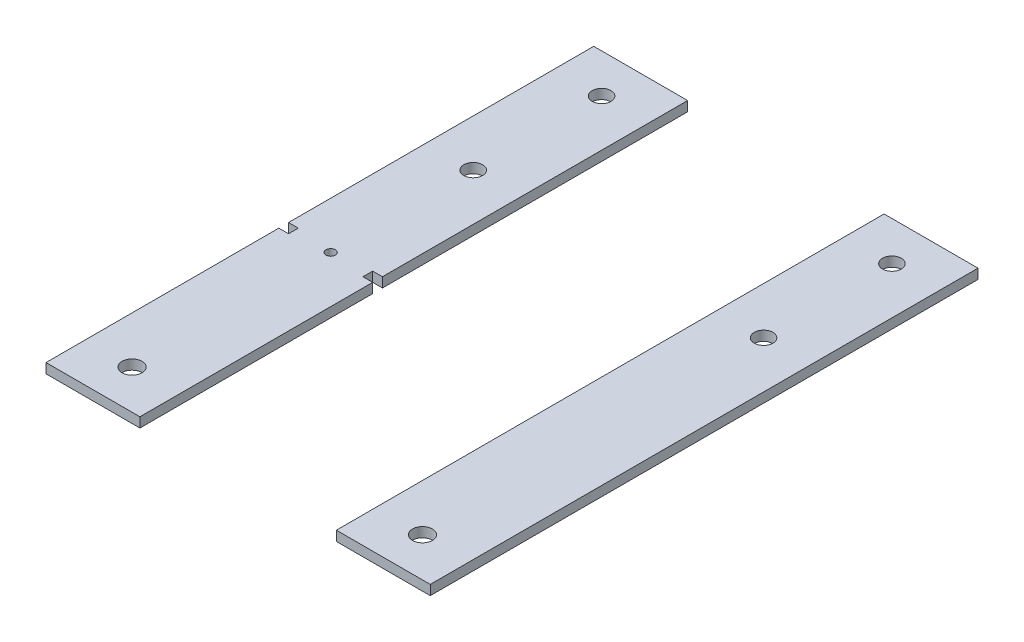
from build123d import *

# Parameters (mm, degrees)
SKETCH1_R             = 1.524
SKETCH1_R_2           = 3.048
SKETCH1_R_3           = 3.2385
BOSS_EXTRUDE1_DEPTH   = 3.175
SKETCH1_W             = 30.48
SKETCH1_H             = 177.8
BOSS_EXTRUDE1_2_DEPTH = 3.175


with BuildPart() as part:
    # Sketch1 → Boss-Extrude1 (new body)
    with BuildSketch(Plane(origin=(0, 0, 0), x_dir=(1, 0, 0), z_dir=(0, 1, 0))):
        Polygon((-31.884999984, 88.9), (-31.884999984, -10.16), (-35.059999984, -10.16), (-35.059999984, -13.335), (-31.884999984, -13.335), (-31.884999984, -88.9), (-62.364999984, -88.9), (-62.364999984, -13.335), (-59.189999984, -13.335), (-59.189999984, -10.16), (-62.364999984, -10.16), (-62.364999984, 88.9), align=None)
        with Locations((-47.124999984, -11.7475)):
            Circle(SKETCH1_R, mode=Mode.SUBTRACT)
        with Locations((-47.124999984, 34.529268)):
            Circle(SKETCH1_R_2, mode=Mode.SUBTRACT)
        with Locations((-47.124999984, 76.2)):
            Circle(SKETCH1_R_2, mode=Mode.SUBTRACT)
        with Locations((-47.124999984, -76.2)):
            Circle(SKETCH1_R_3, mode=Mode.SUBTRACT)
    extrude(amount=BOSS_EXTRUDE1_DEPTH)


with BuildPart() as body_2:
    # Sketch1 → Boss-Extrude1 2 (new body)
    with BuildSketch(Plane(origin=(0, 0, 0), x_dir=(1, 0, 0), z_dir=(0, 1, 0))):
        with Locations((47.124999984, 0)):
            Rectangle(SKETCH1_W, SKETCH1_H)
        with Locations((47.124999984, 76.2)):
            Circle(SKETCH1_R_2, mode=Mode.SUBTRACT)
        with Locations((47.124999984, 34.529268)):
            Circle(SKETCH1_R_2, mode=Mode.SUBTRACT)
        with Locations((47.124999984, -76.2)):
            Circle(SKETCH1_R_3, mode=Mode.SUBTRACT)
    extrude(amount=BOSS_EXTRUDE1_2_DEPTH)


solid = Compound([part.part, body_2.part])
